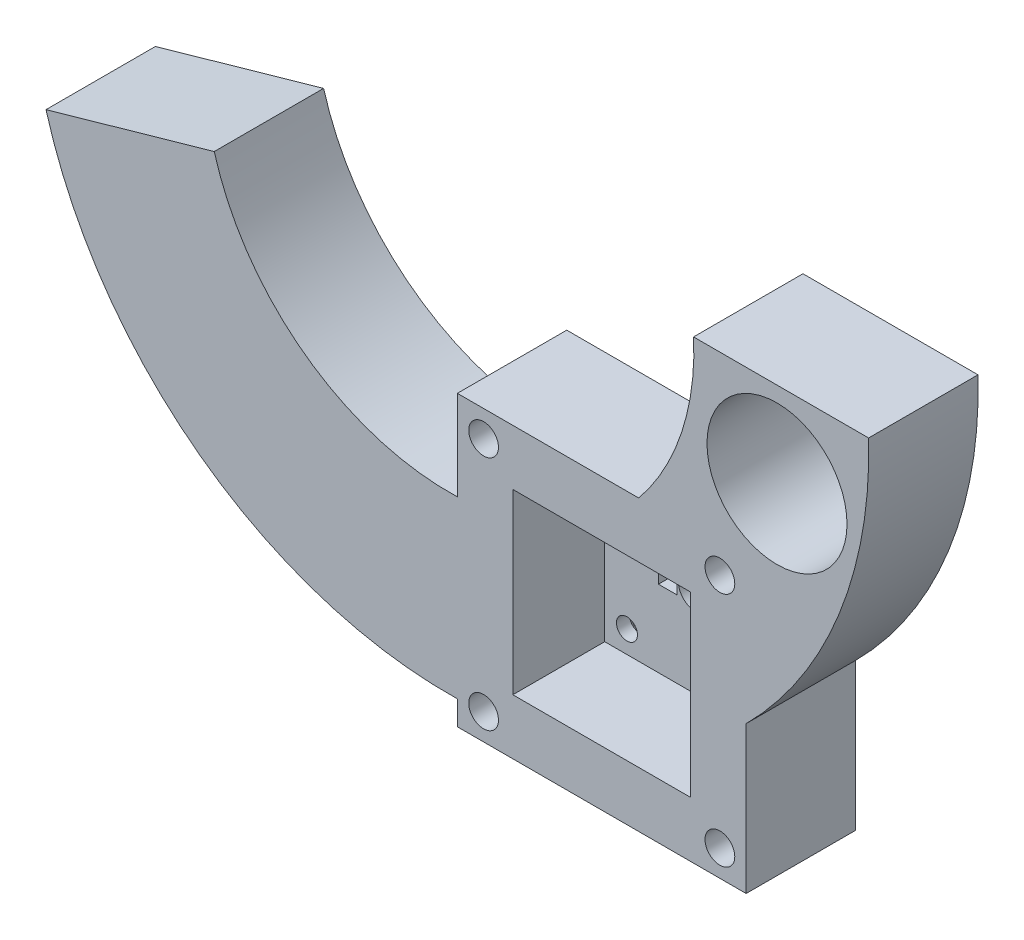
from build123d import *

# Parameters (mm, degrees)
ESQUISSE1_W             = 33
ESQUISSE1_H             = 33
BOSS_EXTRU_1_DEPTH      = 12.5
ESQUISSE3_R             = 2
ESQUISSE3_W             = 2.1
ESQUISSE3_H             = 2.8
ENL_V_MAT_EXTRU_1_DEPTH = 13.5
ESQUISSE2_R             = 1.2
ENL_V_MAT_EXTRU_3_DEPTH = 13.5
ESQUISSE5_W             = 20.32
ESQUISSE5_H             = 20.32
ENL_V_MAT_EXTRU_5_DEPTH = 10.5
ESQUISSE8_R             = 8
BOSS_EXTRU_4_DEPTH      = 12.5
D_GAGEMENT_M31_D        = 3.4
CHANFREIN1_SIZE         = 1
CHANFREIN2_SIZE         = 0.5


with BuildPart() as part:
    # Esquisse1 → Boss.-Extru.1 (new body)
    with BuildSketch(Plane.XY):
        Rectangle(ESQUISSE1_W, ESQUISSE1_H)
    extrude(amount=BOSS_EXTRU_1_DEPTH)

    # Esquisse3 → Enlèv. mat.-Extru.1 (cut, through all)
    with BuildSketch(Plane.XY.offset(12.5)):
        with Locations((0.25, 0)):
            Circle(ESQUISSE3_R)
        with Locations((-2.97, 0)):
            Rectangle(ESQUISSE3_W, ESQUISSE3_H)
    extrude(amount=-ENL_V_MAT_EXTRU_1_DEPTH, mode=Mode.SUBTRACT)

    # Esquisse2 → Enlèv. mat.-Extru.3 (cut, through all)
    with BuildSketch(Plane.XY.offset(12.5)):
        with BuildLine():
            Line((7.62, 8.82), (-7.62, 8.82))
            ThreePointArc((-7.62, 8.82), (-8.82, 7.62), (-7.62, 6.42))
            Line((-7.62, 6.42), (7.62, 6.42))
            ThreePointArc((7.62, 6.42), (8.82, 7.62), (7.62, 8.82))
        make_face()
        with Locations((7.62, -7.62)):
            Circle(ESQUISSE2_R)
        with Locations((-7.62, -7.62)):
            Circle(ESQUISSE2_R)
    extrude(amount=-ENL_V_MAT_EXTRU_3_DEPTH, mode=Mode.SUBTRACT)

    # Esquisse5 → Enlèv. mat.-Extru.5 (cut)
    with BuildSketch(Plane.XY.offset(12.5)):
        Rectangle(ESQUISSE5_W, ESQUISSE5_H)
    extrude(amount=-ENL_V_MAT_EXTRU_5_DEPTH, mode=Mode.SUBTRACT)

    # Esquisse8 → Boss.-Extru.4 (add)
    with BuildSketch(Plane(origin=(0, 0, 0), x_dir=(-1, 0, 0), z_dir=(0, 0, -1))):
        with BuildLine():
            Line((-10.491194523, 35.577324893), (-30.491194523, 35.577324893))
            ThreePointArc((-30.491194523, 35.577324893), (-27.133349226, 16.503433006), (-16.5, 0.31639001))
            Line((-16.5, 0.31639001), (-16.5, 16.5))
            Line((-16.5, 16.5), (-4.221778996, 16.5))
            ThreePointArc((-4.221778996, 16.5), (-9.129954495, 25.455844561), (-10.491194523, 35.577324893))
        make_face()
        with Locations((-20.024037982, 25.814414184)):
            Circle(ESQUISSE8_R, mode=Mode.SUBTRACT)
        with BuildLine():
            Line((44.278689278, 26.536687189), (63.501960696, 21.070416717))
            ThreePointArc((63.501960696, 21.070416717), (45.926381173, -4.33394458), (16.5, -13.734511563))
            Line((16.5, -13.734511563), (16.5, 6.257008408))
            ThreePointArc((16.5, 6.257008408), (33.880318455, 11.614983254), (44.278689278, 26.536687189))
        make_face()
    extrude(amount=-BOSS_EXTRU_4_DEPTH)

    # Dégagement M31 (through all)
    with Locations(Plane(origin=(-13.5, 13.5, 12.5), x_dir=(1, 0, 0), z_dir=(0, 0, 1))):
        with Locations((0, 0), (27, 0), (27, -27), (0, -27)):
            Hole(D_GAGEMENT_M31_D / 2)

    # Chanfrein1
    chanfrein1_edges = [part.edges().sort_by_distance(p)[0] for p in [
        (-11.8, -13.5, 0),
        (15.2, -13.5, 0),
        (15.2, 13.5, 0),
        (-11.8, 13.5, 0),
    ]]
    chamfer(chanfrein1_edges, length=CHANFREIN1_SIZE)

    # Chanfrein2
    chanfrein2_edges = [part.edges().sort_by_distance(p)[0] for p in [
        (6.42, -7.62, 0),
        (-8.82, -7.62, 0),
    ]]
    chamfer(chanfrein2_edges, length=CHANFREIN2_SIZE)


solid = part.part
